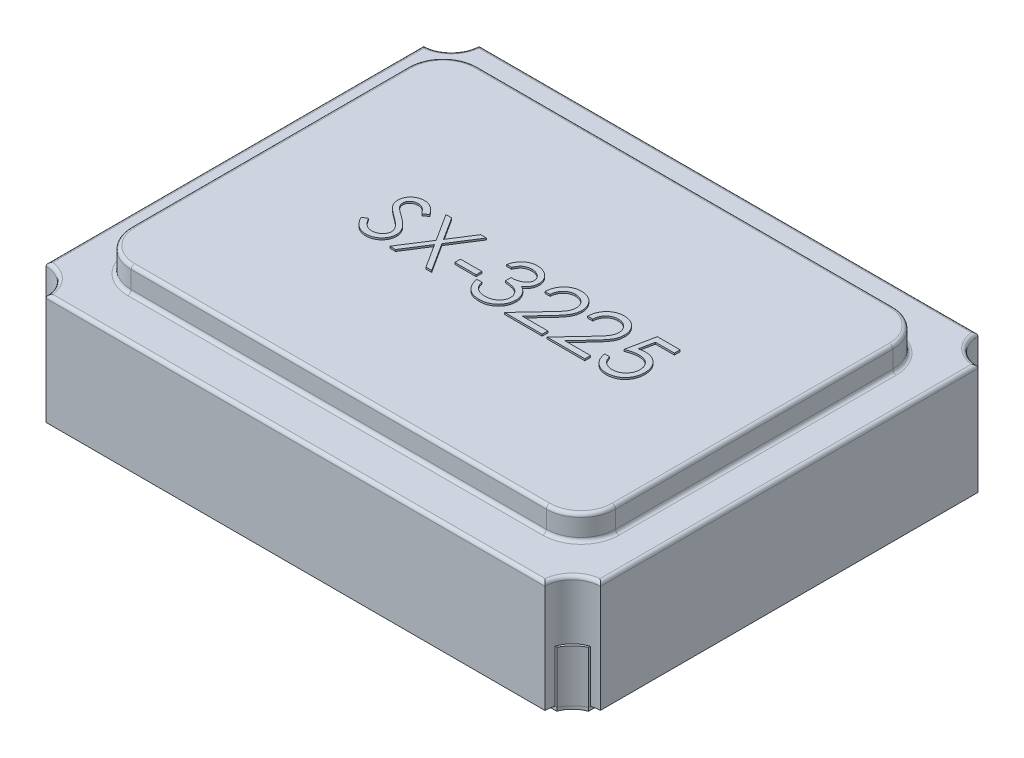
from build123d import *

# Parameters (mm, degrees)
EXTRUDE_2_DEPTH   = 0.02
EXTRUDE_2_2_DEPTH = 0.02
EXTRUDE_4_DEPTH   = 0.3
EXTRUDE_4_2_DEPTH = 0.3
EXTRUDE_4_3_DEPTH = 0.3
EXTRUDE_4_4_DEPTH = 0.3
EXTRUDE_8_DEPTH   = 0.64
SKETCH_7_W        = 2.79580358
SKETCH_7_H        = 2
EXTRUDE_9_DEPTH   = 0.14
FILLET_3_R        = 0.2
FILLET_4_R        = 0.02
FILLET_5_R        = 0.02
FILLET_6_R        = 0.02
SKETCH_8_W        = 0.123076923
SKETCH_8_H        = 0.032820513
EXTRUDE_10_DEPTH  = 0.01


with BuildPart() as part:
    # Эскиз2 → Бобышка-Вытянуть2 (new body)
    with BuildSketch(Plane(origin=(0, 0, 0), x_dir=(1, 0, 0), z_dir=(0, 1, 0))):
        with BuildLine():
            Line((-1.458578644, 1.2), (-0.825, 1.2))
            Line((-0.825, 1.2), (-0.825, 0.198360656))
            ThreePointArc((-0.825, 0.198360656), (-0.626639344, 0), (-0.825, -0.198360656))
            Line((-0.825, -0.198360656), (-0.825, -1.2))
            Line((-0.825, -1.2), (-1.458578644, -1.2))
            ThreePointArc((-1.458578644, -1.2), (-1.493933983, -1.143933983), (-1.55, -1.108578644))
            Line((-1.55, -1.108578644), (-1.55, 1.108578644))
            ThreePointArc((-1.55, 1.108578644), (-1.493933983, 1.143933983), (-1.458578644, 1.2))
        make_face()
    extrude(amount=EXTRUDE_2_DEPTH)


with BuildPart() as body_2:
    # Эскиз2 → Extrude 2 2 (new body)
    with BuildSketch(Plane(origin=(0, 0, 0), x_dir=(1, 0, 0), z_dir=(0, 1, 0))):
        with BuildLine():
            Line((1.55, 1.108578644), (1.55, -1.108578644))
            ThreePointArc((1.55, -1.108578644), (1.493933983, -1.143933983), (1.458578644, -1.2))
            Line((1.458578644, -1.2), (0.825, -1.2))
            Line((0.825, -1.2), (0.825, 1.2))
            Line((0.825, 1.2), (1.458578644, 1.2))
            ThreePointArc((1.458578644, 1.2), (1.493933983, 1.143933983), (1.55, 1.108578644))
        make_face()
    extrude(amount=EXTRUDE_2_2_DEPTH)


with BuildPart() as body_3:
    # Эскиз5 → Бобышка-Вытянуть4 (new body)
    with BuildSketch(Plane(origin=(0, 0.02, 0), x_dir=(-1, 0, 0), z_dir=(0, 1, 0))):
        with BuildLine():
            Line((1.458578644, 1.2), (1.436538459, 1.2))
            ThreePointArc((1.436538459, 1.2), (1.482556073, 1.132556073), (1.55, 1.086538459))
            Line((1.55, 1.086538459), (1.55, 1.108578644))
            ThreePointArc((1.55, 1.108578644), (1.496698209, 1.146698209), (1.458578644, 1.2))
        make_face()
    extrude(amount=EXTRUDE_4_DEPTH)


with BuildPart() as body_4:
    # Эскиз5 → Extrude 4 2 (new body)
    with BuildSketch(Plane(origin=(0, 0.02, 0), x_dir=(-1, 0, 0), z_dir=(0, 1, 0))):
        with BuildLine():
            Line((1.458578644, -1.2), (1.436538459, -1.2))
            ThreePointArc((1.436538459, -1.2), (1.482556073, -1.132556073), (1.55, -1.086538459))
            Line((1.55, -1.086538459), (1.55, -1.108578644))
            ThreePointArc((1.55, -1.108578644), (1.496698209, -1.146698209), (1.458578644, -1.2))
        make_face()
    extrude(amount=EXTRUDE_4_2_DEPTH)


with BuildPart() as body_5:
    # Эскиз5 → Extrude 4 3 (new body)
    with BuildSketch(Plane(origin=(0, 0.02, 0), x_dir=(-1, 0, 0), z_dir=(0, 1, 0))):
        with BuildLine():
            Line((-1.458578644, -1.2), (-1.436538459, -1.2))
            ThreePointArc((-1.436538459, -1.2), (-1.482556073, -1.132556073), (-1.55, -1.086538459))
            Line((-1.55, -1.086538459), (-1.55, -1.108578644))
            ThreePointArc((-1.55, -1.108578644), (-1.496698209, -1.146698209), (-1.458578644, -1.2))
        make_face()
    extrude(amount=EXTRUDE_4_3_DEPTH)


with BuildPart() as body_6:
    # Эскиз5 → Extrude 4 4 (new body)
    with BuildSketch(Plane(origin=(0, 0.02, 0), x_dir=(-1, 0, 0), z_dir=(0, 1, 0))):
        with BuildLine():
            Line((-1.55, 1.108578644), (-1.55, 1.086538459))
            ThreePointArc((-1.55, 1.086538459), (-1.482556073, 1.132556073), (-1.436538459, 1.2))
            Line((-1.436538459, 1.2), (-1.458578644, 1.2))
            ThreePointArc((-1.458578644, 1.2), (-1.496698209, 1.146698209), (-1.55, 1.108578644))
        make_face()
    extrude(amount=EXTRUDE_4_4_DEPTH)


with BuildPart() as body_7:
    # Эскиз6 → Бобышка-Вытянуть8 (new body)
    with BuildSketch(Plane(origin=(0, 0.02, 0), x_dir=(-1, 0, 0), z_dir=(0, 1, 0))):
        with BuildLine():
            Line((1.44, -1.25), (-1.44, -1.25))
            ThreePointArc((-1.44, -1.25), (-1.486862915, -1.136862915), (-1.6, -1.09))
            Line((-1.6, -1.09), (-1.6, 1.09))
            ThreePointArc((-1.6, 1.09), (-1.486862915, 1.136862915), (-1.44, 1.25))
            Line((-1.44, 1.25), (1.44, 1.25))
            ThreePointArc((1.44, 1.25), (1.486862915, 1.136862915), (1.6, 1.09))
            Line((1.6, 1.09), (1.6, -1.09))
            ThreePointArc((1.6, -1.09), (1.486862915, -1.136862915), (1.44, -1.25))
        make_face()
    extrude(amount=EXTRUDE_8_DEPTH)

    # Эскиз7 → Бобышка-Вытянуть9 (add)
    with BuildSketch(Plane(origin=(0, 0.66, 0), x_dir=(-1, 0, 0), z_dir=(0, 1, 0))):
        Rectangle(SKETCH_7_W, SKETCH_7_H)
    extrude(amount=EXTRUDE_9_DEPTH)

    # Скругление3
    fillet_3_edges = [body_7.edges().sort_by_distance(p)[0] for p in [
        (-1.39790179, 0.73, -1),
        (-1.39790179, 0.73, 1),
        (1.39790179, 0.73, 1),
        (1.39790179, 0.73, -1),
    ]]
    fillet(fillet_3_edges, radius=FILLET_3_R)

    # Скругление4
    fillet_4_edges = [body_7.edges().sort_by_distance(p)[0] for p in [
        (0, 0.8, -1),
        (1.39790179, 0.8, 0),
        (-1.39790179, 0.8, 0),
        (0, 0.8, 1),
        (-1.339323146, 0.8, 0.941421356),
        (-1.339323146, 0.8, -0.941421356),
        (1.339323146, 0.8, 0.941421356),
        (1.339323146, 0.8, -0.941421356),
    ]]
    fillet(fillet_4_edges, radius=FILLET_4_R)

    # Скругление5
    fillet_5_edges = [body_7.edges().sort_by_distance(p)[0] for p in [
        (0, 0.66, -1),
        (1.39790179, 0.66, 0),
        (0, 0.66, 1),
        (-1.39790179, 0.66, 0),
        (1.339323146, 0.66, -0.941421356),
        (1.339323146, 0.66, 0.941421356),
        (-1.339323146, 0.66, -0.941421356),
        (-1.339323146, 0.66, 0.941421356),
    ]]
    fillet(fillet_5_edges, radius=FILLET_5_R)

    # Скругление6
    fillet_6_edges = [body_7.edges().sort_by_distance(p)[0] for p in [
        (1.486862915, 0.66, 1.136862915),
        (1.6, 0.66, 0),
        (1.486862915, 0.66, -1.136862915),
        (0, 0.66, -1.25),
        (-1.486862915, 0.66, -1.136862915),
        (-1.6, 0.66, 0),
        (-1.486862915, 0.66, 1.136862915),
        (0, 0.66, 1.25),
    ]]
    fillet(fillet_6_edges, radius=FILLET_6_R)

    # Эскиз8 → Бобышка-Вытянуть10 (add)
    with BuildSketch(Plane(origin=(0, 0.8, 0), x_dir=(-1, 0, 0), z_dir=(0, 1, 0))):
        with BuildLine():
            Line((0.766414632, 0.105091939), (0.73936335, 0.08887399))
            add(Edge.make_bspline(
                [(0.73936335, 0.08887399), (0.736847396, 0.093085591), (0.732026927, 0.101154856), (0.72398566, 0.112058448), (0.715653508, 0.121325846), (0.706968769, 0.128903135), (0.697984454, 0.134868748), (0.688641912, 0.139092952), (0.678972626, 0.141727555), (0.672392163, 0.142047563), (0.669106939, 0.142207324)],
                knots=[0, 0, 0, 0, 1.272034388, 2.437168799, 3.508375237, 4.49857839, 5.41946034, 6.295179144, 7.148887113, 8, 8, 8, 8], degree=3))
            add(Edge.make_bspline(
                [(0.669106939, 0.142207324), (0.666301851, 0.142127323), (0.660740757, 0.141968722), (0.652537891, 0.140506339), (0.644611108, 0.138113891), (0.637039303, 0.134870641), (0.630022727, 0.130884079), (0.623772158, 0.126182832), (0.61849086, 0.120751923), (0.61412466, 0.114787168), (0.610706726, 0.108413077), (0.608274784, 0.101786625), (0.606712558, 0.094950038), (0.60651449, 0.090313907), (0.606414632, 0.087976554)],
                knots=[0, 0, 0, 0, 1.095645842, 2.172120455, 3.244862764, 4.326153987, 5.384857088, 6.392105572, 7.372507978, 8.334705661, 9.272564127, 10.189475455, 11.087205874, 12, 12, 12, 12], degree=3))
            add(Edge.make_bspline(
                [(0.606414632, 0.087976554), (0.606546531, 0.085311359), (0.606813641, 0.079914047), (0.609167698, 0.071937323), (0.612762245, 0.064009345), (0.616140716, 0.059104456), (0.617888991, 0.056566298)],
                knots=[0, 0, 0, 0, 0.938992559, 1.901562324, 2.914110574, 4, 4, 4, 4], degree=3))
            add(Edge.make_bspline(
                [(0.617888991, 0.056566298), (0.619317466, 0.054729467), (0.622325174, 0.050861949), (0.62757201, 0.045206113), (0.633537993, 0.039217626), (0.640377584, 0.033016017), (0.647991049, 0.026474429), (0.656464701, 0.019714182), (0.665699598, 0.01263445), (0.672213239, 0.007958491), (0.675581298, 0.005540657)],
                knots=[0, 0, 0, 0, 0.722283655, 1.520795216, 2.39349503, 3.346893347, 4.386874146, 5.510198126, 6.712579003, 8, 8, 8, 8], degree=3))
            add(Edge.make_bspline(
                [(0.675581298, 0.005540657), (0.678947615, 0.003142066), (0.685383755, -0.001443858), (0.694391488, -0.008241268), (0.702435585, -0.014495636), (0.709557034, -0.020119842), (0.715571595, -0.025359184), (0.720699142, -0.029932863), (0.724750501, -0.034085108), (0.727004987, -0.03677658), (0.728017196, -0.037984984)],
                knots=[0, 0, 0, 0, 1.452255772, 2.776602448, 3.96446981, 5.032613149, 5.964194703, 6.766668629, 7.446264616, 8, 8, 8, 8], degree=3))
            add(Edge.make_bspline(
                [(0.728017196, -0.037984984), (0.729431591, -0.039868601), (0.73221319, -0.043572986), (0.735888889, -0.049361355), (0.738988617, -0.05527542), (0.741483317, -0.061336615), (0.743500688, -0.067499387), (0.744903277, -0.073810002), (0.745767804, -0.080225622), (0.745857107, -0.084542135), (0.745901811, -0.086702933)],
                knots=[0, 0, 0, 0, 1.068019517, 2.100403715, 3.106014851, 4.09224787, 5.069873182, 6.043214339, 7.020455327, 8, 8, 8, 8], degree=3))
            add(Edge.make_bspline(
                [(0.745901811, -0.086702933), (0.745783004, -0.090088802), (0.745547928, -0.096788171), (0.743543451, -0.106569638), (0.740417007, -0.115937276), (0.73589376, -0.124682595), (0.730306703, -0.132793199), (0.723674855, -0.140125211), (0.715874022, -0.146426255), (0.707189702, -0.151782646), (0.697795058, -0.156055852), (0.687921838, -0.159169577), (0.677614407, -0.16099441), (0.670609823, -0.161251813), (0.667055657, -0.16138242)],
                knots=[0, 0, 0, 0, 1.005367131, 1.989245246, 2.955191616, 3.932180104, 4.904534562, 5.875498653, 6.859376768, 7.874484044, 8.900379497, 9.918679785, 10.943926428, 12, 12, 12, 12], degree=3))
            add(Edge.make_bspline(
                [(0.667055657, -0.16138242), (0.663283603, -0.16125655), (0.655803168, -0.161006935), (0.644796583, -0.158703118), (0.634136209, -0.155123587), (0.625592755, -0.150860434), (0.618903785, -0.146648447), (0.61380809, -0.14280227), (0.608616185, -0.138383946), (0.60338401, -0.133299876), (0.598059871, -0.127651878), (0.592668305, -0.121392104), (0.587158851, -0.114576974), (0.583615657, -0.109710526), (0.581799247, -0.107215753)],
                knots=[0, 0, 0, 0, 1.286534051, 2.551350862, 3.822568981, 5.117864672, 5.799956111, 6.519305446, 7.295594771, 8.126302591, 9.008831062, 9.944975596, 10.946496709, 12, 12, 12, 12], degree=3))
            Line((0.581799247, -0.107215753), (0.607760786, -0.087536266))
            add(Edge.make_bspline(
                [(0.607760786, -0.087536266), (0.609328299, -0.08955592), (0.612346964, -0.093445302), (0.616931752, -0.098890267), (0.621246476, -0.103870759), (0.625530057, -0.108185316), (0.629452302, -0.112157077), (0.633326724, -0.115497085), (0.637003649, -0.118311376), (0.641627791, -0.121318686), (0.647500465, -0.12422828), (0.654803689, -0.126729838), (0.662440803, -0.128267193), (0.667625471, -0.128462589), (0.670260786, -0.128561907)],
                knots=[0, 0, 0, 0, 1.181426797, 2.275151783, 3.28963443, 4.225459815, 5.084396437, 5.868484344, 6.587427557, 7.222918358, 8.415355282, 9.605213164, 10.782753814, 12, 12, 12, 12], degree=3))
            add(Edge.make_bspline(
                [(0.670260786, -0.128561907), (0.673567305, -0.128452937), (0.679943616, -0.128242799), (0.688975021, -0.125887382), (0.697150696, -0.122306129), (0.704158536, -0.117142), (0.709944802, -0.110985363), (0.714182305, -0.103964152), (0.716715834, -0.096209498), (0.717025934, -0.090802688), (0.717183862, -0.088049087)],
                knots=[0, 0, 0, 0, 1.144248881, 2.206576175, 3.214949548, 4.222996039, 5.203671638, 6.127710127, 7.046472867, 8, 8, 8, 8], degree=3))
            add(Edge.make_bspline(
                [(0.717183862, -0.088049087), (0.717144168, -0.086335509), (0.717064225, -0.082884484), (0.716111115, -0.077796311), (0.714688798, -0.072768037), (0.712672703, -0.067770692), (0.709932807, -0.062661907), (0.706211546, -0.057470801), (0.701554881, -0.052067452), (0.697981013, -0.048556572), (0.696094119, -0.046702933)],
                knots=[0, 0, 0, 0, 0.858500039, 1.728959331, 2.587258638, 3.476905708, 4.426389682, 5.487945037, 6.673710648, 8, 8, 8, 8], degree=3))
            add(Edge.make_bspline(
                [(0.696094119, -0.046702933), (0.695393651, -0.046077833), (0.693729498, -0.04459274), (0.690687128, -0.042161446), (0.6866695, -0.039162335), (0.681781528, -0.035451495), (0.675933083, -0.031146904), (0.669123524, -0.026303602), (0.661428755, -0.02076436), (0.655968466, -0.016891671), (0.653081298, -0.014843958)],
                knots=[0, 0, 0, 0, 0.420754252, 0.999615792, 1.744751191, 2.668019286, 3.750313428, 4.999500688, 6.413464383, 8, 8, 8, 8], degree=3))
            add(Edge.make_bspline(
                [(0.653081298, -0.014843958), (0.649608303, -0.012316747), (0.642883329, -0.007423151), (0.633314603, -7.0885e-05), (0.624638711, 0.007119851), (0.616824551, 0.014102669), (0.609797075, 0.020826163), (0.603627123, 0.027366009), (0.598286701, 0.033679321), (0.592458838, 0.041718339), (0.586574424, 0.051682995), (0.581529023, 0.063897082), (0.578319225, 0.076146219), (0.577902361, 0.084368473), (0.577696683, 0.088425272)],
                knots=[0, 0, 0, 0, 1.163604038, 2.253157948, 3.268574773, 4.215621239, 5.091738613, 5.902582348, 6.650434646, 7.330118262, 8.591011492, 9.77460283, 10.902005569, 12, 12, 12, 12], degree=3))
            add(Edge.make_bspline(
                [(0.577696683, 0.088425272), (0.577756859, 0.091294098), (0.577876042, 0.09697604), (0.579242521, 0.105320132), (0.581251722, 0.113420659), (0.584246196, 0.121176812), (0.587989375, 0.128675035), (0.592546666, 0.13590218), (0.598069583, 0.142739498), (0.604204881, 0.149319771), (0.611019645, 0.155270978), (0.618231057, 0.160571624), (0.625798641, 0.165110156), (0.633808816, 0.168675727), (0.642129635, 0.171527879), (0.650800155, 0.173572227), (0.659839007, 0.174831202), (0.66598314, 0.17496156), (0.669106939, 0.175027836)],
                knots=[0, 0, 0, 0, 0.98378539, 1.948466333, 2.894822735, 3.844243623, 4.795447569, 5.768042124, 6.770299647, 7.807997672, 8.852593179, 9.870666288, 10.876941106, 11.874841786, 12.874492863, 13.892063892, 14.928283473, 16, 16, 16, 16], degree=3))
            add(Edge.make_bspline(
                [(0.669106939, 0.175027836), (0.671523778, 0.174980564), (0.676327019, 0.174886615), (0.683412523, 0.174075723), (0.690367915, 0.17288654), (0.697105864, 0.171073468), (0.703710262, 0.168821915), (0.710122268, 0.166065234), (0.716357351, 0.162783468), (0.722423211, 0.158971541), (0.72837537, 0.154577284), (0.734189805, 0.149503652), (0.739895622, 0.143774929), (0.745516524, 0.137399087), (0.750920102, 0.13027074), (0.75624224, 0.122502933), (0.761455226, 0.114070573), (0.764730619, 0.108140718), (0.766414632, 0.105091939)],
                knots=[0, 0, 0, 0, 0.915366252, 1.81920441, 2.69897508, 3.586533125, 4.459536084, 5.340758185, 6.227946952, 7.126403341, 8.052553006, 9.028121456, 10.047063623, 11.114014537, 12.24582441, 13.433687931, 14.680555077, 16, 16, 16, 16], degree=3))
        make_face()
        Polygon((0.53461976, -0.153177292), (0.501478734, -0.153177292), (0.417696683, -0.022279856), (0.333914632, -0.153177292), (0.300773606, -0.153177292), (0.401094119, 0.00361758), (0.296671042, 0.166822708), (0.329812068, 0.166822708), (0.417696683, 0.029515016), (0.505581298, 0.166822708), (0.538722324, 0.166822708), (0.434235144, 0.00361758), align=None)
        with Locations((0.208465914, 0.043745786)):
            Rectangle(SKETCH_8_W, SKETCH_8_H)
        with BuildLine():
            Line((0.081286427, -0.079331138), (0.110004375, -0.079331138))
            add(Edge.make_bspline(
                [(0.110004375, -0.079331138), (0.109226359, -0.082552394), (0.107705401, -0.088849685), (0.104533052, -0.09784692), (0.10107712, -0.106361071), (0.096927259, -0.114232712), (0.092400744, -0.12162004), (0.087214667, -0.128355503), (0.081608292, -0.134610403), (0.075407154, -0.140161327), (0.068903962, -0.145187862), (0.062007083, -0.149473582), (0.054855275, -0.153160362), (0.047398989, -0.15619764), (0.039616024, -0.158485688), (0.031576745, -0.160145739), (0.023260082, -0.161223783), (0.017614588, -0.161328996), (0.014747965, -0.16138242)],
                knots=[0, 0, 0, 0, 1.162005537, 2.271625781, 3.343758855, 4.383309926, 5.390229558, 6.379919256, 7.361854164, 8.333198761, 9.295911338, 10.242430842, 11.177959212, 12.116337295, 13.062827104, 14.020064771, 14.994644689, 16, 16, 16, 16], degree=3))
            add(Edge.make_bspline(
                [(0.014747965, -0.16138242), (0.010571257, -0.161256319), (0.002308948, -0.161006867), (-0.009829388, -0.158728976), (-0.021534697, -0.155124393), (-0.032678857, -0.150143937), (-0.043030257, -0.144001097), (-0.052240422, -0.136690036), (-0.060184515, -0.128351814), (-0.066849144, -0.119141979), (-0.072067429, -0.10929919), (-0.075915326, -0.09916889), (-0.07825788, -0.08877511), (-0.078561474, -0.081757301), (-0.078713573, -0.078241394)],
                knots=[0, 0, 0, 0, 1.083050992, 2.142477498, 3.193116406, 4.255571735, 5.30263384, 6.308962982, 7.297363603, 8.282367274, 9.249857812, 10.179914175, 11.08814088, 12, 12, 12, 12], degree=3))
            add(Edge.make_bspline(
                [(-0.078713573, -0.078241394), (-0.078607188, -0.074857916), (-0.078399008, -0.068236974), (-0.076631355, -0.058571008), (-0.073656611, -0.049460919), (-0.069535947, -0.040868356), (-0.064201862, -0.032847799), (-0.057740359, -0.025381203), (-0.05010583, -0.018435452), (-0.044320327, -0.014456528), (-0.041341779, -0.012408061)],
                knots=[0, 0, 0, 0, 1.024540389, 2.004866551, 2.965041327, 3.920577974, 4.882998113, 5.874504559, 6.905732034, 8, 8, 8, 8], degree=3))
            add(Edge.make_bspline(
                [(-0.041341779, -0.012408061), (-0.044750164, -0.010770301), (-0.051514104, -0.007520167), (-0.060640634, -0.001044879), (-0.069051925, 0.006247902), (-0.073687608, 0.012002632), (-0.076021266, 0.014899631)],
                knots=[0, 0, 0, 0, 1.015663554, 2.015584519, 3.001021554, 4, 4, 4, 4], degree=3))
            add(Edge.make_bspline(
                [(-0.076021266, 0.014899631), (-0.077561672, 0.017007544), (-0.080617261, 0.021188851), (-0.08437821, 0.027915463), (-0.087829134, 0.034694364), (-0.090368914, 0.041792092), (-0.092560644, 0.048980654), (-0.094002729, 0.056413986), (-0.09492849, 0.064021467), (-0.095058486, 0.069170422), (-0.09512383, 0.071758606)],
                knots=[0, 0, 0, 0, 1.02516404, 2.033540309, 3.025129118, 4.011046665, 4.991655828, 5.976607087, 6.982917762, 8, 8, 8, 8], degree=3))
            add(Edge.make_bspline(
                [(-0.09512383, 0.071758606), (-0.094959375, 0.076239293), (-0.09463124, 0.085179582), (-0.091710926, 0.098391717), (-0.087155605, 0.111282785), (-0.080807011, 0.123669968), (-0.07291667, 0.13522446), (-0.063581322, 0.145592347), (-0.052791029, 0.154422998), (-0.040859956, 0.161866687), (-0.027883823, 0.167765727), (-0.014059974, 0.172016463), (0.000529743, 0.174566308), (0.010506991, 0.174872242), (0.015581298, 0.175027836)],
                knots=[0, 0, 0, 0, 0.955619592, 1.906742024, 2.874954321, 3.868585453, 4.869520953, 5.854611167, 6.836527075, 7.836578462, 8.849204403, 9.870874567, 10.917152508, 12, 12, 12, 12], degree=3))
            add(Edge.make_bspline(
                [(0.015581298, 0.175027836), (0.019002276, 0.174947765), (0.02573362, 0.17479021), (0.035633235, 0.173732312), (0.045062857, 0.171747619), (0.054114049, 0.169251593), (0.062650209, 0.165800557), (0.07079412, 0.161686283), (0.078510085, 0.156803266), (0.085752282, 0.151143294), (0.092512973, 0.144807801), (0.098619917, 0.137691537), (0.104140683, 0.129927317), (0.109040191, 0.121445301), (0.113339062, 0.112269244), (0.116944783, 0.102362377), (0.120093024, 0.091801502), (0.121559605, 0.084443866), (0.122312068, 0.080668862)],
                knots=[0, 0, 0, 0, 1.048603596, 2.063302207, 3.045874044, 3.999447474, 4.937100059, 5.862643889, 6.7929026, 7.7308982, 8.676022965, 9.627908155, 10.600123445, 11.591992905, 12.626222643, 13.701663232, 14.820785756, 16, 16, 16, 16], degree=3))
            Line((0.122312068, 0.080668862), (0.093594119, 0.080668862))
            add(Edge.make_bspline(
                [(0.093594119, 0.080668862), (0.092845932, 0.083132772), (0.091390644, 0.08792529), (0.088913451, 0.09482269), (0.086091209, 0.101145712), (0.083063592, 0.10694074), (0.079883849, 0.112264845), (0.076325913, 0.116977245), (0.072653305, 0.121284921), (0.069884907, 0.123711857), (0.068530016, 0.124899631)],
                knots=[0, 0, 0, 0, 1.198163088, 2.33053128, 3.407730985, 4.417276592, 5.372219308, 6.28897303, 7.162600585, 8, 8, 8, 8], degree=3))
            add(Edge.make_bspline(
                [(0.068530016, 0.124899631), (0.066738129, 0.126280395), (0.063159886, 0.129037661), (0.057332651, 0.132566358), (0.051182743, 0.135586838), (0.044658876, 0.138042012), (0.037760175, 0.139884953), (0.030514624, 0.141211416), (0.022910335, 0.142087087), (0.017720556, 0.14216666), (0.015068478, 0.142207324)],
                knots=[0, 0, 0, 0, 0.946083416, 1.889246487, 2.84504177, 3.809995578, 4.801312957, 5.829064617, 6.89060985, 8, 8, 8, 8], degree=3))
            add(Edge.make_bspline(
                [(0.015068478, 0.142207324), (0.012073831, 0.142151104), (0.006218059, 0.142041171), (-0.002325819, 0.141027255), (-0.010456524, 0.139557046), (-0.018091081, 0.137257354), (-0.025333378, 0.134498492), (-0.032021747, 0.130886636), (-0.038352817, 0.126807628), (-0.044141117, 0.122062958), (-0.049359552, 0.116934483), (-0.053868856, 0.111493628), (-0.05777443, 0.105909095), (-0.060913859, 0.100050609), (-0.063397295, 0.093975635), (-0.065086894, 0.087661436), (-0.066261968, 0.081161181), (-0.066357648, 0.076742523), (-0.066405881, 0.074515016)],
                knots=[0, 0, 0, 0, 1.216990249, 2.379719373, 3.493992396, 4.571561497, 5.616923107, 6.638958652, 7.655775068, 8.674704564, 9.676001865, 10.625896028, 11.54399481, 12.441854662, 13.322657739, 14.20572845, 15.095482574, 16, 16, 16, 16], degree=3))
            add(Edge.make_bspline(
                [(-0.066405881, 0.074515016), (-0.066265676, 0.071533595), (-0.065985963, 0.065585589), (-0.063859266, 0.056831462), (-0.060329867, 0.048393634), (-0.055484932, 0.040382607), (-0.049445804, 0.033044794), (-0.042497954, 0.026476661), (-0.034493134, 0.02100768), (-0.027083793, 0.017239623), (-0.020503779, 0.014729116), (-0.014884113, 0.01296867), (-0.008587102, 0.011561435), (-0.00168841, 0.010200203), (0.005841079, 0.009059036), (0.014008143, 0.008103263), (0.02281607, 0.007339696), (0.028913536, 0.006998521), (0.032055657, 0.006822708)],
                knots=[0, 0, 0, 0, 1.070440979, 2.135555593, 3.216243406, 4.345886539, 5.486149072, 6.621334998, 7.769144672, 8.957074012, 9.598644492, 10.297969361, 11.070758978, 11.915404831, 12.824182859, 13.805940418, 14.869366021, 16, 16, 16, 16], degree=3))
            Line((0.032055657, 0.006822708), (0.032055657, -0.025997805))
            add(Edge.make_bspline(
                [(0.032055657, -0.025997805), (0.028098233, -0.026074961), (0.020349323, -0.02622604), (0.008998326, -0.027677019), (-0.00182272, -0.030032164), (-0.011951052, -0.033320253), (-0.021134915, -0.037323241), (-0.029178675, -0.041805058), (-0.035792957, -0.046975546), (-0.041096223, -0.052590288), (-0.045029713, -0.058650469), (-0.047933183, -0.064938059), (-0.049650524, -0.071570029), (-0.049880186, -0.076095095), (-0.049995625, -0.078369599)],
                knots=[0, 0, 0, 0, 1.321816535, 2.58820849, 3.816448615, 5.017641336, 6.139869627, 7.160068286, 8.085608132, 8.934319198, 9.728416342, 10.48890201, 11.240453369, 12, 12, 12, 12], degree=3))
            add(Edge.make_bspline(
                [(-0.049995625, -0.078369599), (-0.049958569, -0.08004099), (-0.049884849, -0.083366141), (-0.048918015, -0.088239284), (-0.047532292, -0.092963519), (-0.045519117, -0.097483649), (-0.04291547, -0.101814041), (-0.039765445, -0.105970512), (-0.036061063, -0.109992753), (-0.031826378, -0.113792052), (-0.027100362, -0.117211489), (-0.022072697, -0.120259869), (-0.016723784, -0.122823123), (-0.011088479, -0.124947886), (-0.005136321, -0.126543406), (0.001101377, -0.127689753), (0.007637438, -0.128406279), (0.012096562, -0.128509457), (0.01436335, -0.128561907)],
                knots=[0, 0, 0, 0, 0.884246871, 1.759167212, 2.622361933, 3.489113179, 4.372562419, 5.294145153, 6.247651513, 7.265905295, 8.30305477, 9.334068495, 10.37719476, 11.441246459, 12.52060732, 13.637552802, 14.799054011, 16, 16, 16, 16], degree=3))
            add(Edge.make_bspline(
                [(0.01436335, -0.128561907), (0.018007051, -0.128434944), (0.025124048, -0.128186954), (0.03538202, -0.126007241), (0.044908349, -0.12255371), (0.05216549, -0.118383581), (0.057533513, -0.114281291), (0.061442996, -0.110752092), (0.065212138, -0.106750702), (0.068693035, -0.102167369), (0.072094268, -0.097159694), (0.075383363, -0.091700098), (0.078454672, -0.085710743), (0.080324228, -0.081498856), (0.081286427, -0.079331138)],
                knots=[0, 0, 0, 0, 1.4727372, 2.876598283, 4.222346151, 5.558423782, 6.24313385, 6.953189256, 7.68715613, 8.463578749, 9.278833271, 10.135787152, 11.040551781, 12, 12, 12, 12], degree=3))
        make_face()
        with BuildLine():
            Line((-0.16486742, -0.054715753), (-0.136149471, -0.054715753))
            add(Edge.make_bspline(
                [(-0.136149471, -0.054715753), (-0.136336607, -0.058525682), (-0.136704138, -0.06600828), (-0.138426033, -0.076917629), (-0.140887567, -0.087346458), (-0.144376136, -0.097205359), (-0.148684213, -0.106612106), (-0.153958546, -0.115441788), (-0.160086695, -0.123782037), (-0.167057417, -0.131474947), (-0.174621294, -0.138507228), (-0.182733004, -0.144644226), (-0.191309177, -0.149770063), (-0.200275424, -0.154078448), (-0.209735444, -0.157308488), (-0.21959881, -0.159706177), (-0.229910103, -0.161148508), (-0.236935468, -0.161303562), (-0.240508445, -0.16138242)],
                knots=[0, 0, 0, 0, 1.100776268, 2.161895295, 3.184016182, 4.190939212, 5.176500551, 6.166955529, 7.155448256, 8.160289653, 9.16017456, 10.133824356, 11.091467644, 12.04088621, 13.000931625, 13.972173743, 14.968683325, 16, 16, 16, 16], degree=3))
            add(Edge.make_bspline(
                [(-0.240508445, -0.16138242), (-0.244017545, -0.161300942), (-0.2509128, -0.161140841), (-0.260972119, -0.159745259), (-0.270571123, -0.157606655), (-0.279601024, -0.15443758), (-0.288154497, -0.150461085), (-0.296125633, -0.145515792), (-0.303707185, -0.139835696), (-0.310527062, -0.133135745), (-0.316791942, -0.125986879), (-0.322191889, -0.118351951), (-0.326842367, -0.1104572), (-0.330648637, -0.102240958), (-0.333533959, -0.093676466), (-0.335671707, -0.084845838), (-0.336893758, -0.07564716), (-0.337080282, -0.069420096), (-0.337175112, -0.066254215)],
                knots=[0, 0, 0, 0, 1.111674182, 2.184400057, 3.212814286, 4.223731311, 5.211378316, 6.196328225, 7.191884489, 8.207283132, 9.220262353, 10.201199469, 11.166417575, 12.120932471, 13.06540007, 14.026332106, 14.996573967, 16, 16, 16, 16], degree=3))
            add(Edge.make_bspline(
                [(-0.337175112, -0.066254215), (-0.337020297, -0.061797272), (-0.336713384, -0.052961599), (-0.334088105, -0.039977355), (-0.329987717, -0.027397492), (-0.325051253, -0.017272594), (-0.320069936, -0.009114875), (-0.315585536, -0.002394897), (-0.310305948, 0.00483881), (-0.304276279, 0.012615522), (-0.29739269, 0.020833397), (-0.289834014, 0.029660103), (-0.281405047, 0.038932426), (-0.275494315, 0.045269674), (-0.272431522, 0.048553477)],
                knots=[0, 0, 0, 0, 1.184416499, 2.348048165, 3.509039915, 4.696071444, 5.333504901, 6.05069495, 6.844171097, 7.714965912, 8.667477798, 9.695072654, 10.805644396, 12, 12, 12, 12], degree=3))
            Line((-0.272431522, 0.048553477), (-0.19236742, 0.134002195))
            Line((-0.19236742, 0.134002195), (-0.341277676, 0.134002195))
            Line((-0.341277676, 0.134002195), (-0.341277676, 0.166822708))
            Line((-0.341277676, 0.166822708), (-0.123841779, 0.166822708))
            Line((-0.123841779, 0.166822708), (-0.247944343, 0.034386811))
            add(Edge.make_bspline(
                [(-0.247944343, 0.034386811), (-0.250966078, 0.031232852), (-0.256770212, 0.025174743), (-0.264976091, 0.016327409), (-0.272358144, 0.008129252), (-0.278921269, 0.000543945), (-0.284670867, -0.00638551), (-0.289588541, -0.012713419), (-0.293696025, -0.018385477), (-0.298049103, -0.025048774), (-0.302200052, -0.03319392), (-0.305848311, -0.043097645), (-0.308056918, -0.053315299), (-0.308323214, -0.060217996), (-0.308457163, -0.063690112)],
                knots=[0, 0, 0, 0, 1.329530082, 2.553755191, 3.672934919, 4.687409497, 5.60679272, 6.413407421, 7.126401618, 7.737995624, 8.834647426, 9.90044882, 10.943907757, 12, 12, 12, 12], degree=3))
            add(Edge.make_bspline(
                [(-0.308457163, -0.063690112), (-0.308399635, -0.065873796), (-0.308286259, -0.070177416), (-0.307266703, -0.076483052), (-0.305768772, -0.082589158), (-0.303459999, -0.088420236), (-0.300686092, -0.094090971), (-0.297142222, -0.099428957), (-0.29309251, -0.104616152), (-0.288395041, -0.109474691), (-0.283238094, -0.113925868), (-0.2777893, -0.117868557), (-0.272024765, -0.121163583), (-0.265968513, -0.123864697), (-0.259637502, -0.125983591), (-0.253019468, -0.127451803), (-0.246132701, -0.12837363), (-0.24143021, -0.128498355), (-0.239034086, -0.128561907)],
                knots=[0, 0, 0, 0, 0.991504627, 1.954065223, 2.895985987, 3.842598665, 4.797835564, 5.759220273, 6.74786863, 7.784730864, 8.824135544, 9.839918996, 10.835834653, 11.835434876, 12.84861661, 13.863796685, 14.911511676, 16, 16, 16, 16], degree=3))
            add(Edge.make_bspline(
                [(-0.239034086, -0.128561907), (-0.236530971, -0.128499132), (-0.231615266, -0.128375852), (-0.224413431, -0.127441494), (-0.217495029, -0.126026457), (-0.210966671, -0.123773728), (-0.204691728, -0.121137204), (-0.198830279, -0.117723369), (-0.193217668, -0.113822534), (-0.187966738, -0.109274409), (-0.183184275, -0.104140261), (-0.178833626, -0.098551831), (-0.175147278, -0.092410048), (-0.171874943, -0.085862286), (-0.169372254, -0.078728651), (-0.167232634, -0.071183605), (-0.165678445, -0.063119497), (-0.165142251, -0.057563527), (-0.16486742, -0.054715753)],
                knots=[0, 0, 0, 0, 1.031072318, 2.024855787, 2.988461151, 3.935103592, 4.865765533, 5.788564469, 6.724086513, 7.67908574, 8.64457978, 9.611397706, 10.591395687, 11.591555111, 12.622101007, 13.700900657, 14.821571223, 16, 16, 16, 16], degree=3))
        make_face()
        with BuildLine():
            Line((-0.411021266, -0.054715753), (-0.382303317, -0.054715753))
            add(Edge.make_bspline(
                [(-0.382303317, -0.054715753), (-0.382490453, -0.058525682), (-0.382857984, -0.06600828), (-0.384579879, -0.076917629), (-0.387041413, -0.087346458), (-0.390529982, -0.097205359), (-0.394838059, -0.106612106), (-0.400112392, -0.115441788), (-0.406240541, -0.123782037), (-0.413211264, -0.131474947), (-0.42077514, -0.138507228), (-0.428886851, -0.144644226), (-0.437463023, -0.149770063), (-0.44642927, -0.154078448), (-0.455889291, -0.157308488), (-0.465752656, -0.159706177), (-0.476063949, -0.161148508), (-0.483089314, -0.161303562), (-0.486662291, -0.16138242)],
                knots=[0, 0, 0, 0, 1.100776268, 2.161895295, 3.184016182, 4.190939212, 5.176500551, 6.166955529, 7.155448256, 8.160289653, 9.16017456, 10.133824356, 11.091467644, 12.04088621, 13.000931625, 13.972173743, 14.968683325, 16, 16, 16, 16], degree=3))
            add(Edge.make_bspline(
                [(-0.486662291, -0.16138242), (-0.490171391, -0.161300942), (-0.497066646, -0.161140841), (-0.507125965, -0.159745259), (-0.516724969, -0.157606655), (-0.52575487, -0.15443758), (-0.534308343, -0.150461085), (-0.54227948, -0.145515792), (-0.549861031, -0.139835696), (-0.556680908, -0.133135745), (-0.562945788, -0.125986879), (-0.568345735, -0.118351951), (-0.572996213, -0.1104572), (-0.576802483, -0.102240958), (-0.579687805, -0.093676466), (-0.581825553, -0.084845838), (-0.583047605, -0.07564716), (-0.583234128, -0.069420096), (-0.583328958, -0.066254215)],
                knots=[0, 0, 0, 0, 1.111674182, 2.184400057, 3.212814286, 4.223731311, 5.211378316, 6.196328225, 7.191884489, 8.207283132, 9.220262353, 10.201199469, 11.166417575, 12.120932471, 13.06540007, 14.026332106, 14.996573967, 16, 16, 16, 16], degree=3))
            add(Edge.make_bspline(
                [(-0.583328958, -0.066254215), (-0.583174143, -0.061797272), (-0.58286723, -0.052961599), (-0.580241951, -0.039977355), (-0.576141563, -0.027397492), (-0.571205099, -0.017272594), (-0.566223782, -0.009114875), (-0.561739382, -0.002394897), (-0.556459794, 0.00483881), (-0.550430125, 0.012615522), (-0.543546536, 0.020833397), (-0.53598786, 0.029660103), (-0.527558894, 0.038932426), (-0.521648162, 0.045269674), (-0.518585368, 0.048553477)],
                knots=[0, 0, 0, 0, 1.184416499, 2.348048165, 3.509039915, 4.696071444, 5.333504901, 6.05069495, 6.844171097, 7.714965912, 8.667477798, 9.695072654, 10.805644396, 12, 12, 12, 12], degree=3))
            Line((-0.518585368, 0.048553477), (-0.438521266, 0.134002195))
            Line((-0.438521266, 0.134002195), (-0.587431522, 0.134002195))
            Line((-0.587431522, 0.134002195), (-0.587431522, 0.166822708))
            Line((-0.587431522, 0.166822708), (-0.369995625, 0.166822708))
            Line((-0.369995625, 0.166822708), (-0.494098189, 0.034386811))
            add(Edge.make_bspline(
                [(-0.494098189, 0.034386811), (-0.497119924, 0.031232852), (-0.502924058, 0.025174743), (-0.511129937, 0.016327409), (-0.51851199, 0.008129252), (-0.525075116, 0.000543945), (-0.530824713, -0.00638551), (-0.535742387, -0.012713419), (-0.539849872, -0.018385477), (-0.54420295, -0.025048774), (-0.548353898, -0.03319392), (-0.552002158, -0.043097645), (-0.554210764, -0.053315299), (-0.55447706, -0.060217996), (-0.554611009, -0.063690112)],
                knots=[0, 0, 0, 0, 1.329530082, 2.553755191, 3.672934919, 4.687409497, 5.60679272, 6.413407421, 7.126401618, 7.737995624, 8.834647426, 9.90044882, 10.943907757, 12, 12, 12, 12], degree=3))
            add(Edge.make_bspline(
                [(-0.554611009, -0.063690112), (-0.554553481, -0.065873796), (-0.554440105, -0.070177416), (-0.553420549, -0.076483052), (-0.551922618, -0.082589158), (-0.549613845, -0.088420236), (-0.546839938, -0.094090971), (-0.543296068, -0.099428957), (-0.539246356, -0.104616152), (-0.534548888, -0.109474691), (-0.52939194, -0.113925868), (-0.523943146, -0.117868557), (-0.518178612, -0.121163583), (-0.51212236, -0.123864697), (-0.505791349, -0.125983591), (-0.499173314, -0.127451803), (-0.492286547, -0.12837363), (-0.487584056, -0.128498355), (-0.485187932, -0.128561907)],
                knots=[0, 0, 0, 0, 0.991504627, 1.954065223, 2.895985987, 3.842598665, 4.797835564, 5.759220273, 6.74786863, 7.784730864, 8.824135544, 9.839918996, 10.835834653, 11.835434876, 12.84861661, 13.863796685, 14.911511676, 16, 16, 16, 16], degree=3))
            add(Edge.make_bspline(
                [(-0.485187932, -0.128561907), (-0.482684817, -0.128499132), (-0.477769112, -0.128375852), (-0.470567277, -0.127441494), (-0.463648875, -0.126026457), (-0.457120517, -0.123773728), (-0.450845574, -0.121137204), (-0.444984125, -0.117723369), (-0.439371514, -0.113822534), (-0.434120584, -0.109274409), (-0.429338121, -0.104140261), (-0.424987472, -0.098551831), (-0.421301124, -0.092410048), (-0.41802879, -0.085862286), (-0.4155261, -0.078728651), (-0.41338648, -0.071183605), (-0.411832291, -0.063119497), (-0.411296098, -0.057563527), (-0.411021266, -0.054715753)],
                knots=[0, 0, 0, 0, 1.031072318, 2.024855787, 2.988461151, 3.935103592, 4.865765533, 5.788564469, 6.724086513, 7.67908574, 8.64457978, 9.611397706, 10.591395687, 11.591555111, 12.622101007, 13.700900657, 14.821571223, 16, 16, 16, 16], degree=3))
        make_face()
        with BuildLine():
            Line((-0.817175112, -0.153177292), (-0.817175112, -0.120356779))
            Line((-0.817175112, -0.120356779), (-0.708328958, -0.120356779))
            Line((-0.708328958, -0.120356779), (-0.691085368, -0.036190112))
            add(Edge.make_bspline(
                [(-0.691085368, -0.036190112), (-0.694473334, -0.037125451), (-0.701036982, -0.038937523), (-0.71072474, -0.040949479), (-0.719921742, -0.04216232), (-0.725889776, -0.042327925), (-0.728777676, -0.042408061)],
                knots=[0, 0, 0, 0, 1.100273476, 2.13160584, 3.095893838, 4, 4, 4, 4], degree=3))
            add(Edge.make_bspline(
                [(-0.728777676, -0.042408061), (-0.73235169, -0.042333252), (-0.739379095, -0.04218616), (-0.749645264, -0.04069057), (-0.759493984, -0.038522867), (-0.768783594, -0.035188526), (-0.777663862, -0.031090459), (-0.786014393, -0.025995848), (-0.793874414, -0.019977288), (-0.801226742, -0.013158243), (-0.807855125, -0.005565983), (-0.813638032, 0.002603967), (-0.818581032, 0.011260442), (-0.822524081, 0.020483068), (-0.825721032, 0.03018493), (-0.82783486, 0.040447439), (-0.829245196, 0.051185208), (-0.829402559, 0.058527388), (-0.829482804, 0.062271426)],
                knots=[0, 0, 0, 0, 1.052656913, 2.069786496, 3.052102726, 4.020122636, 4.972424848, 5.930457368, 6.896570172, 7.885826804, 8.881139003, 9.861434336, 10.831623367, 11.813212553, 12.812997731, 13.836986694, 14.897002833, 16, 16, 16, 16], degree=3))
            add(Edge.make_bspline(
                [(-0.829482804, 0.062271426), (-0.829421951, 0.064879159), (-0.829301066, 0.070059384), (-0.828687478, 0.077752757), (-0.827502244, 0.085282371), (-0.825928017, 0.092633312), (-0.82383474, 0.09981655), (-0.821359336, 0.106849034), (-0.818396444, 0.113719129), (-0.815015378, 0.120392649), (-0.811168613, 0.126738244), (-0.80706325, 0.132829853), (-0.802589829, 0.138490752), (-0.79782666, 0.143815565), (-0.792682287, 0.148651139), (-0.787282952, 0.153199194), (-0.781507915, 0.157266815), (-0.775458986, 0.16100786), (-0.769140409, 0.164357512), (-0.762487997, 0.167151703), (-0.755647821, 0.16960084), (-0.748558905, 0.171592491), (-0.741234985, 0.173137724), (-0.733650841, 0.174190006), (-0.725844529, 0.174955634), (-0.72055311, 0.175003605), (-0.71788024, 0.175027836)],
                knots=[0, 0, 0, 0, 1.056281413, 2.098288097, 3.122646807, 4.141030392, 5.140675379, 6.150604744, 7.15845591, 8.168533554, 9.177684096, 10.161739049, 11.141561652, 12.097360316, 13.052218386, 13.998410789, 14.954052752, 15.909851415, 16.877523809, 17.846742625, 18.829312613, 19.818263486, 20.826374662, 21.858017533, 22.918014209, 24, 24, 24, 24], degree=3))
            add(Edge.make_bspline(
                [(-0.71788024, 0.175027836), (-0.714691829, 0.174964499), (-0.708419006, 0.174839889), (-0.699227339, 0.173542414), (-0.6903893, 0.171671438), (-0.681941544, 0.168900973), (-0.6739238, 0.165267954), (-0.666219761, 0.160979145), (-0.658970451, 0.155802723), (-0.652124438, 0.149924259), (-0.645844376, 0.143404306), (-0.640062872, 0.136472615), (-0.635056814, 0.128975443), (-0.630707043, 0.121037868), (-0.627006794, 0.112639195), (-0.624097326, 0.103759931), (-0.621749774, 0.094443208), (-0.620756522, 0.088029194), (-0.620252035, 0.084771426)],
                knots=[0, 0, 0, 0, 1.04695683, 2.059763882, 3.044413726, 4.012427942, 4.974081556, 5.932886124, 6.904940154, 7.895678616, 8.893654631, 9.876199664, 10.857615262, 11.850515636, 12.847107701, 13.868396357, 14.917328757, 16, 16, 16, 16], degree=3))
            Line((-0.620252035, 0.084771426), (-0.648969984, 0.084771426))
            add(Edge.make_bspline(
                [(-0.648969984, 0.084771426), (-0.649675708, 0.0878236), (-0.651032148, 0.093690048), (-0.654025051, 0.101922477), (-0.657626502, 0.109289076), (-0.662107571, 0.115743516), (-0.667197585, 0.121503056), (-0.673072284, 0.126624859), (-0.679681748, 0.131189895), (-0.68702745, 0.135026169), (-0.694796931, 0.13825294), (-0.70288107, 0.140556819), (-0.711165074, 0.141951136), (-0.716742447, 0.142121606), (-0.719546907, 0.142207324)],
                knots=[0, 0, 0, 0, 1.136370375, 2.184166959, 3.172867797, 4.104539607, 5.027679118, 5.956634301, 6.927059835, 7.936867459, 8.959641981, 9.976160943, 10.98235693, 12, 12, 12, 12], degree=3))
            add(Edge.make_bspline(
                [(-0.719546907, 0.142207324), (-0.722285732, 0.142131653), (-0.727678502, 0.141982658), (-0.735618876, 0.140854382), (-0.743262602, 0.139071066), (-0.750623249, 0.136572741), (-0.757664648, 0.133267604), (-0.764376843, 0.129207433), (-0.770855456, 0.124493527), (-0.776929979, 0.119105704), (-0.782492149, 0.113164947), (-0.787407071, 0.106812904), (-0.79150094, 0.10003646), (-0.794950921, 0.092953213), (-0.79757065, 0.085485456), (-0.79943954, 0.077668206), (-0.800536963, 0.069482151), (-0.800687928, 0.063898671), (-0.800764856, 0.061053477)],
                knots=[0, 0, 0, 0, 1.027268864, 2.022700798, 3.002744649, 3.968653148, 4.933396556, 5.915045722, 6.907600446, 7.935526002, 8.956456544, 9.95700807, 10.942805781, 11.92166854, 12.907987664, 13.905483474, 14.932689774, 16, 16, 16, 16], degree=3))
            add(Edge.make_bspline(
                [(-0.800764856, 0.061053477), (-0.800716232, 0.058484691), (-0.800621404, 0.053474955), (-0.79949994, 0.04615235), (-0.797989418, 0.039162519), (-0.795607052, 0.032570772), (-0.792713331, 0.026308291), (-0.788942933, 0.020529814), (-0.784774513, 0.014952797), (-0.779782546, 0.009945947), (-0.774377396, 0.005286241), (-0.768387513, 0.001334155), (-0.761984077, -0.002028335), (-0.755152165, -0.004782889), (-0.747884192, -0.006977214), (-0.740176013, -0.008493713), (-0.732025937, -0.009401171), (-0.72645102, -0.009524271), (-0.723585368, -0.009587548)],
                knots=[0, 0, 0, 0, 1.045820996, 2.039596555, 3.013371638, 3.9552447, 4.890047302, 5.817684688, 6.761648481, 7.722253242, 8.692244539, 9.66551337, 10.63924952, 11.635311376, 12.662847378, 13.728455105, 14.832366986, 16, 16, 16, 16], degree=3))
            add(Edge.make_bspline(
                [(-0.723585368, -0.009587548), (-0.721083469, -0.009536268), (-0.715961693, -0.00943129), (-0.708086971, -0.008605133), (-0.69984783, -0.007334169), (-0.691212284, -0.005502306), (-0.682204031, -0.003208687), (-0.672808091, -0.000344244), (-0.663024236, 0.002955234), (-0.656439001, 0.00551442), (-0.653072548, 0.006822708)],
                knots=[0, 0, 0, 0, 0.824638674, 1.688163388, 2.607705698, 3.571998603, 4.597075385, 5.671199175, 6.809488238, 8, 8, 8, 8], degree=3))
            Line((-0.653072548, 0.006822708), (-0.685893061, -0.153177292))
            Line((-0.685893061, -0.153177292), (-0.817175112, -0.153177292))
        make_face()
    extrude(amount=EXTRUDE_10_DEPTH)


solid = Compound([part.part, body_2.part, body_3.part, body_4.part, body_5.part, body_6.part, body_7.part])
